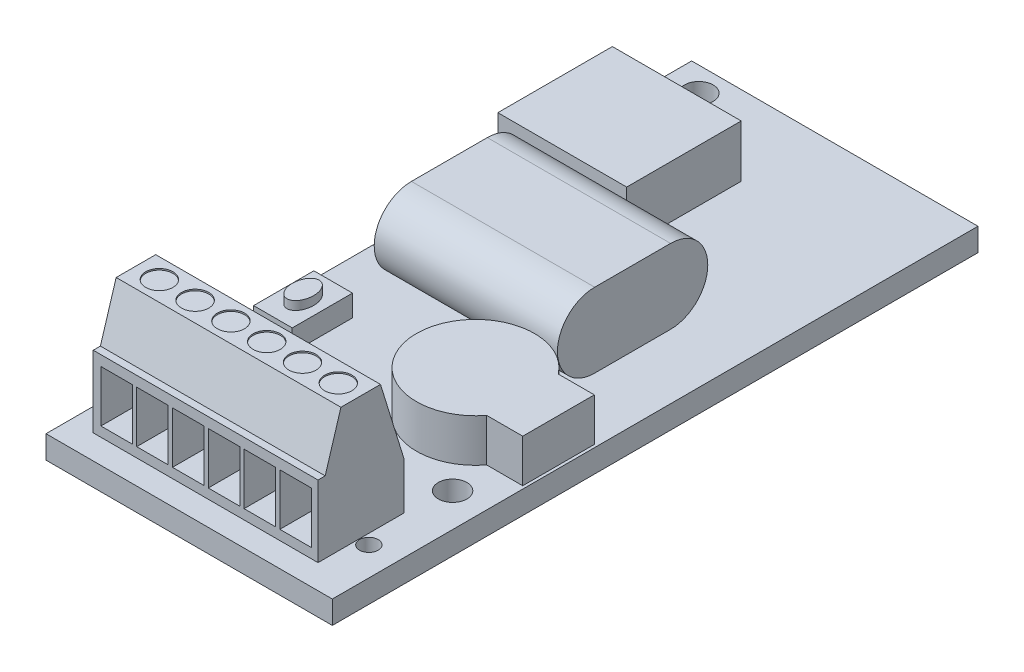
from build123d import *

# Parameters (mm, degrees)
SKETCH1_W           = 20
SKETCH1_H           = 45.1
SKETCH1_R           = 1
SKETCH1_R_2         = 0.65
BOSS_EXTRUDE1_DEPTH = 1.6
SKETCH2_W           = 15.7
SKETCH2_H           = 6
BOSS_EXTRUDE2_DEPTH = 8.6
CUT_EXTRUDE1_DEPTH  = 18.3
SKETCH4_W           = 2.2
SKETCH4_H           = 3.601430215
CUT_EXTRUDE2_DEPTH  = 4
SKETCH5_R           = 0.95
CUT_EXTRUDE3_DEPTH  = 0.1
SKETCH6_W           = 2.7
SKETCH6_H           = 4.21
BOSS_EXTRUDE3_DEPTH = 1.5
SKETCH7_RX          = 1.124329337
SKETCH7_RY          = 0.743812381
BOSS_EXTRUDE4_DEPTH = 0.6
BOSS_EXTRUDE5_DEPTH = 3
BOSS_EXTRUDE6_DEPTH = 12.8
SKETCH10_W          = 9
SKETCH10_H          = 8
BOSS_EXTRUDE7_DEPTH = 3.65


with BuildPart() as part:
    # Sketch1 → Boss-Extrude1 (new body)
    with BuildSketch(Plane(origin=(0, 0, 0), x_dir=(1, 0, 0), z_dir=(0, 1, 0))):
        with Locations((10, 22.55)):
            Rectangle(SKETCH1_W, SKETCH1_H)
        with Locations(Location((2.2, 43.4, 0), (0, 0, 270))):  # turned: the seam where the file's is
            Circle(SKETCH1_R, mode=Mode.SUBTRACT)
        with Locations(Location((17.65, 10.75, 0), (0, 0, 270))):  # turned: the seam where the file's is
            Circle(SKETCH1_R, mode=Mode.SUBTRACT)
        with Locations(Location((18, 4.55, 0), (0, 0, 270))):  # turned: the seam where the file's is
            Circle(SKETCH1_R_2, mode=Mode.SUBTRACT)
    extrude(amount=BOSS_EXTRUDE1_DEPTH)

    # Sketch2 → Boss-Extrude2 (add)
    with BuildSketch(Plane(origin=(0, 1.6, 0), x_dir=(1, 0, 0), z_dir=(0, 1, 0))):
        with Locations((9.45, 4.7)):
            Rectangle(SKETCH2_W, SKETCH2_H)
    extrude(amount=BOSS_EXTRUDE2_DEPTH)

    # Sketch3 → Cut-Extrude1 (cut, through all)
    with BuildSketch(Plane(origin=(17.3, 0, 0), x_dir=(0, 0, -1), z_dir=(1, 0, 0))):
        Polygon((1.7, 6.6), (2.2, 6.6), (3.3, 10.2), (1.7, 10.2), align=None)
        Polygon((6.063741388, 10.2), (7.7, 10.2), (7.7, 4.901672733), align=None)
    extrude(amount=-CUT_EXTRUDE1_DEPTH, mode=Mode.SUBTRACT)

    # Sketch4 → Cut-Extrude2 (cut)
    with BuildSketch(Plane.XY.offset(-1.7)):
        with Locations((5.735754943, 4.083777336)):
            Rectangle(SKETCH4_W, SKETCH4_H)
        with Locations((3.235754943, 4.083777336)):
            Rectangle(SKETCH4_W, SKETCH4_H)
        with Locations((8.235754943, 4.083777336)):
            Rectangle(SKETCH4_W, SKETCH4_H)
        with Locations((10.735754943, 4.083777336)):
            Rectangle(SKETCH4_W, SKETCH4_H)
        with Locations((13.235754943, 4.083777336)):
            Rectangle(SKETCH4_W, SKETCH4_H)
        with Locations((15.735754943, 4.083777336)):
            Rectangle(SKETCH4_W, SKETCH4_H)
    extrude(amount=-CUT_EXTRUDE2_DEPTH, mode=Mode.SUBTRACT)

    # Sketch5 → Cut-Extrude3 (cut)
    with BuildSketch(Plane(origin=(0, 10.2, 0), x_dir=(1, 0, 0), z_dir=(0, 1, 0))):
        with Locations(Location((3.235754943, 4.681870694, 0), (0, 0, 270))):  # turned: the seam where the file's is
            Circle(SKETCH5_R)
        with Locations(Location((5.735754943, 4.681870694, 0), (0, 0, 270))):  # turned: the seam where the file's is
            Circle(SKETCH5_R)
        with Locations(Location((8.235754943, 4.681870694, 0), (0, 0, 270))):  # turned: the seam where the file's is
            Circle(SKETCH5_R)
        with Locations(Location((10.735754943, 4.681870694, 0), (0, 0, 270))):  # turned: the seam where the file's is
            Circle(SKETCH5_R)
        with Locations(Location((13.235754943, 4.681870694, 0), (0, 0, 270))):  # turned: the seam where the file's is
            Circle(SKETCH5_R)
        with Locations(Location((15.735754943, 4.681870694, 0), (0, 0, 270))):  # turned: the seam where the file's is
            Circle(SKETCH5_R)
    extrude(amount=-CUT_EXTRUDE3_DEPTH, mode=Mode.SUBTRACT)

    # Sketch6 → Boss-Extrude3 (add)
    with BuildSketch(Plane(origin=(0, 1.6, 0), x_dir=(1, 0, 0), z_dir=(0, 1, 0))):
        with Locations((2.35, 15.605)):
            Rectangle(SKETCH6_W, SKETCH6_H)
    extrude(amount=BOSS_EXTRUDE3_DEPTH)

    # Sketch7 → Boss-Extrude4 (add)
    with BuildSketch(Plane(origin=(0, 3.1, 0), x_dir=(1, 0, 0), z_dir=(0, 1, 0))):
        with Locations(Location((2.35, 15.605), (0, 0, 90))):
            Ellipse(SKETCH7_RX, SKETCH7_RY)
    extrude(amount=BOSS_EXTRUDE4_DEPTH)

    # Sketch8 → Boss-Extrude5 (add)
    with BuildSketch(Plane(origin=(0, 1.6, 0), x_dir=(1, 0, 0), z_dir=(0, 1, 0))):
        with BuildLine():
            Line((17.281101187, 13.5), (19.8, 13.5))
            Line((19.8, 13.5), (19.8, 18.5))
            Line((19.8, 18.5), (17.281101187, 18.5))
            ThreePointArc((17.281101187, 18.5), (9.875, 16), (17.281101187, 13.5))
        make_face()
    extrude(amount=BOSS_EXTRUDE5_DEPTH)

    # Sketch9 → Boss-Extrude6 (add)
    with BuildSketch(Plane(origin=(15.5, 0, 0), x_dir=(0, 0, -1), z_dir=(1, 0, 0))):
        with BuildLine():
            Line((22.825, 6.8), (28.125, 6.8))
            ThreePointArc((28.125, 6.8), (30.725, 4.2), (28.125, 1.6))
            Line((28.125, 1.6), (22.825, 1.6))
            ThreePointArc((22.825, 1.6), (20.225, 4.2), (22.825, 6.8))
        make_face()
    extrude(amount=-BOSS_EXTRUDE6_DEPTH)

    # Sketch10 → Boss-Extrude7 (add)
    with BuildSketch(Plane(origin=(0, 1.6, 0), x_dir=(1, 0, 0), z_dir=(0, 1, 0))):
        with Locations((4.51, 35.55)):
            Rectangle(SKETCH10_W, SKETCH10_H)
    extrude(amount=BOSS_EXTRUDE7_DEPTH)


solid = part.part
